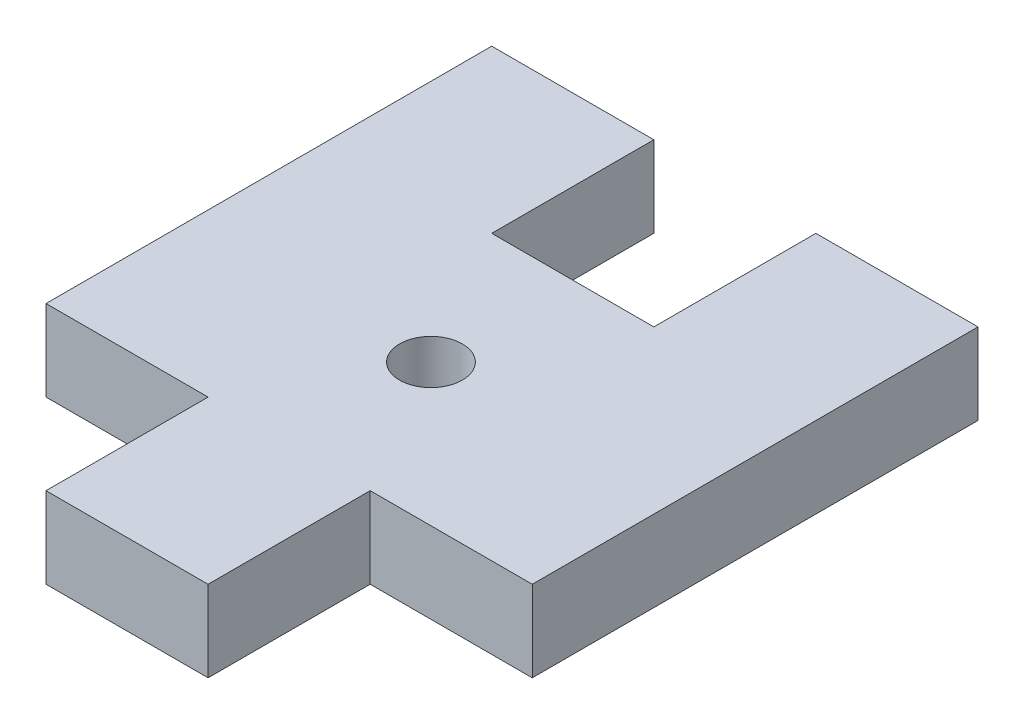
from build123d import *

# Parameters (mm, degrees)
SKETCH_1_R      = 1.55
EXTRUDE_1_DEPTH = 4


with BuildPart() as part:
    # 草圖1 → 填料-伸長1 (new body)
    with BuildSketch(Plane(origin=(0, 4, 0), x_dir=(1, 0, 0), z_dir=(0, 1, 0))):
        Polygon((-4, 7), (-4, 15), (-12, 15), (-12, -7), (-4, -7), (-4, -15), (4, -15), (4, -7), (12, -7), (12, 15), (4, 15), (4, 7), align=None)
        Circle(SKETCH_1_R, mode=Mode.SUBTRACT)
    extrude(amount=-EXTRUDE_1_DEPTH)


solid = part.part
